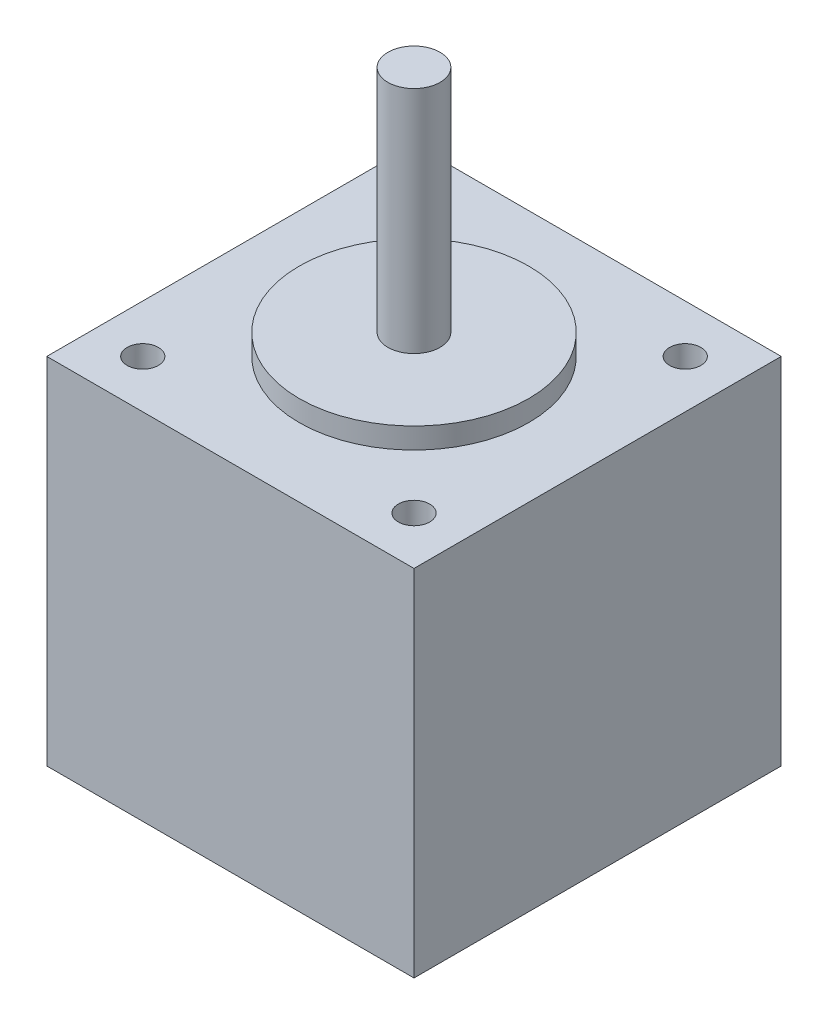
from build123d import *

# Parameters (mm, degrees)
SKETCH1_W           = 35.2
SKETCH1_H           = 35.2
BOSS_EXTRUDE1_DEPTH = 34
SKETCH2_R           = 1.5
CUT_EXTRUDE1_DEPTH  = 4.5
SKETCH3_R           = 11
BOSS_EXTRUDE2_DEPTH = 2
SKETCH4_R           = 2.5
BOSS_EXTRUDE3_DEPTH = 22


with BuildPart() as part:
    # Sketch1 → Boss-Extrude1 (new body)
    with BuildSketch(Plane(origin=(0, 0, 0), x_dir=(1, 0, 0), z_dir=(0, 1, 0))):
        Rectangle(SKETCH1_W, SKETCH1_H)
    extrude(amount=BOSS_EXTRUDE1_DEPTH)

    # Sketch2 → Cut-Extrude1 (cut)
    with BuildSketch(Plane(origin=(0, 34, 0), x_dir=(1, 0, 0), z_dir=(0, 1, 0))):
        with Locations((-13, 13)):
            Circle(SKETCH2_R)
        with Locations((13, 13)):
            Circle(SKETCH2_R)
    cut_extrude1 = extrude(amount=-CUT_EXTRUDE1_DEPTH, mode=Mode.SUBTRACT)

    # Mirror1: Cut-Extrude1 across plane
    add(cut_extrude1.mirror(Plane.XY), mode=Mode.SUBTRACT)

    # Sketch3 → Boss-Extrude2 (add)
    with BuildSketch(Plane(origin=(0, 34, 0), x_dir=(1, 0, 0), z_dir=(0, 1, 0))):
        Circle(SKETCH3_R)
    extrude(amount=BOSS_EXTRUDE2_DEPTH)

    # Sketch4 → Boss-Extrude3 (add)
    with BuildSketch(Plane(origin=(0, 36, 0), x_dir=(1, 0, 0), z_dir=(0, 1, 0))):
        Circle(SKETCH4_R)
    extrude(amount=BOSS_EXTRUDE3_DEPTH)


solid = part.part
